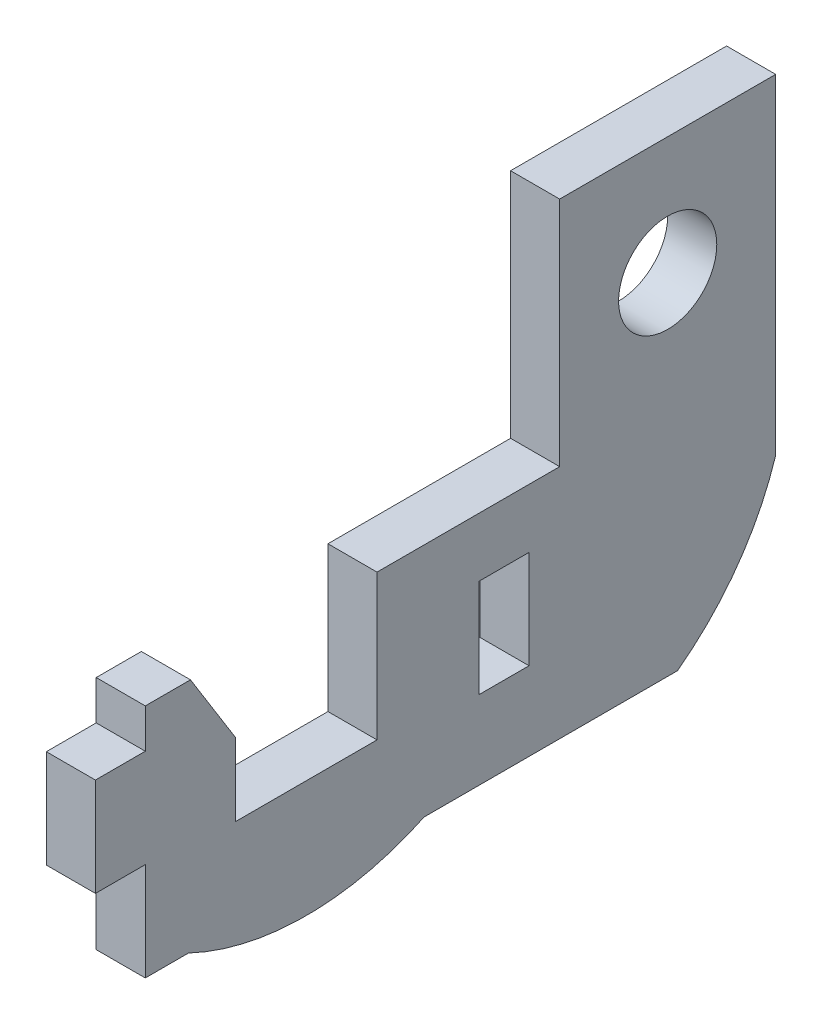
from build123d import *

# Parameters (mm, degrees)
SKETCH1_R                = 3.175
SKETCH1_W                = 3.2258
SKETCH1_H                = 6.35
BOSS_EXTRUDE1_DEPTH      = 3.175
ADD_BODY_AT_BOTTOM_DEPTH = 3.175
CUT_EXTRUDE1_DEPTH       = 4.175


with BuildPart() as part:
    # Sketch1 → Boss-Extrude1 (new body)
    with BuildSketch(Plane(origin=(0, 0, 0), x_dir=(0, 0, -1), z_dir=(1, 0, 0))):
        Polygon((-6.985, 7.62), (6.985, 7.62), (6.985, -22.606), (-33.782, -22.606), (-33.782, -16.256), (-37.0078, -16.256), (-37.0078, -9.906), (-33.782, -9.906), (-33.782, -7.366), (-27.94, -7.366), (-27.94, -16.764), (-18.796, -16.764), (-18.796, -7.366), (-6.985, -7.366), align=None)
        Circle(SKETCH1_R, mode=Mode.SUBTRACT)
        with Locations((-10.5791, -14.351)):
            Rectangle(SKETCH1_W, SKETCH1_H, mode=Mode.SUBTRACT)
    extrude(amount=BOSS_EXTRUDE1_DEPTH)

    # Sketch2 → add body at bottom (add)
    with BuildSketch(Plane.ZY):
        with BuildLine():
            Line((23.368, -22.606), (15.748, -22.606))
            ThreePointArc((15.748, -22.606), (23.368, -24.321629486), (30.988, -22.606))
            Line((30.988, -22.606), (23.368, -22.606))
        make_face()
    extrude(amount=-ADD_BODY_AT_BOTTOM_DEPTH)

    # Sketch3 → Cut-Extrude1 (cut, through all)
    with BuildSketch(Plane.ZY):
        Polygon((30.861, -7.366), (27.94, -12.065), (27.94, -7.366), align=None)
        with BuildLine():
            Line((-6.985, -22.606), (-0.635, -22.606))
            ThreePointArc((-0.635, -22.606), (-4.50973023, -18.660807307), (-6.985, -13.716))
            Line((-6.985, -13.716), (-6.985, -22.606))
        make_face()
    extrude(amount=-CUT_EXTRUDE1_DEPTH, mode=Mode.SUBTRACT)


solid = part.part
